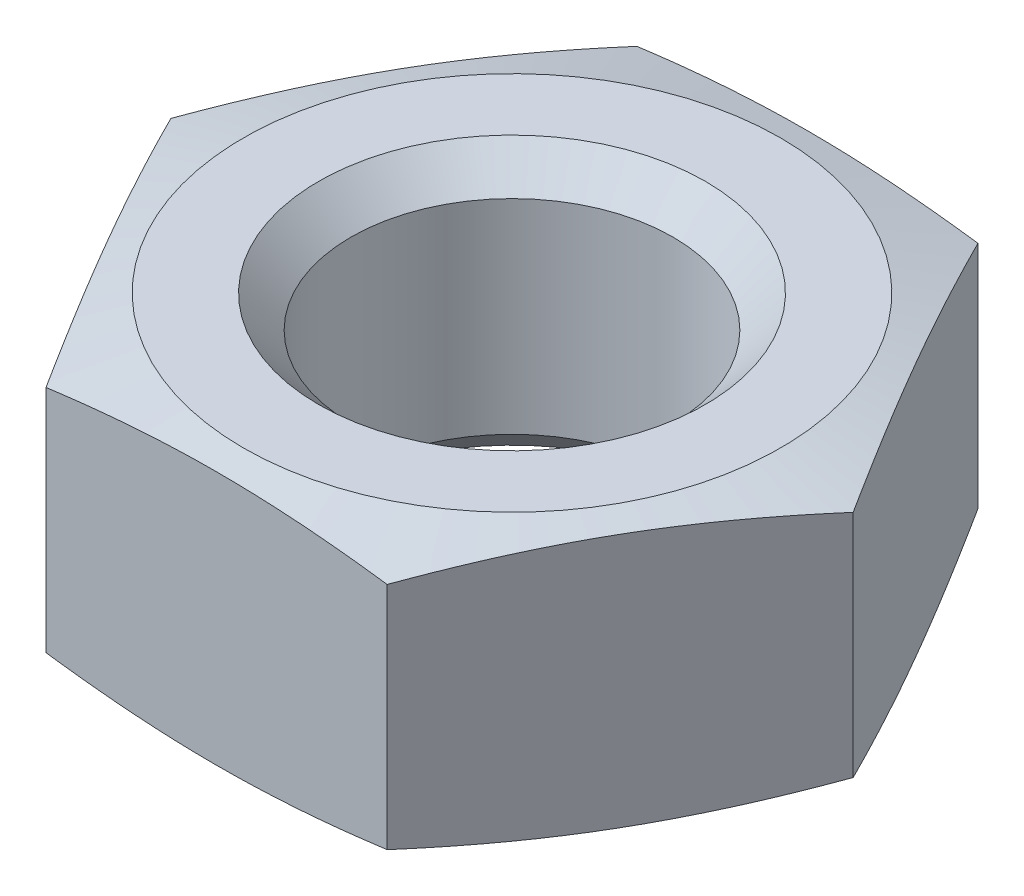
from build123d import *

# Parameters (mm, degrees)
SKETCH1_R      = 1.5
EXTRUDE1_DEPTH = 2.5


with BuildPart() as part:
    # Sketch1 → Extrude1 (new body)
    with BuildSketch(Plane(origin=(0, 0, 0), x_dir=(1, 0, 0), z_dir=(0, 1, 0))):
        Polygon((-3.175426481, 0), (-1.58771324, 2.75), (1.58771324, 2.75), (3.175426481, 0), (1.58771324, -2.75), (-1.58771324, -2.75), align=None)
        with Locations(Location((0, 0, 0), (0, 0, 270))):  # turned: the seam where the file's is
            Circle(SKETCH1_R, mode=Mode.SUBTRACT)
    extrude(amount=EXTRUDE1_DEPTH)

    # Sketch2 → Cut-Revolve1 (revolve, cut)
    with BuildSketch(Plane.XY, mode=Mode.PRIVATE) as cut_revolve1_sk:
        Polygon((1.5, 2.5), (1.8, 2.5), (1.5, 2.2), align=None)
        Polygon((1.5, 0), (1.8, 0), (1.5, 0.3), align=None)
        Polygon((3.175426481, 0), (3.175426481, 0.18097998), (2.5, 0), align=None)
        Polygon((3.175426481, 2.5), (3.175426481, 2.31902002), (2.5, 2.5), align=None)
    revolve(cut_revolve1_sk.sketch.rotate(Axis((0, 0, 0), (0, 1, 0)), 90), axis=Axis((0, 0, 0), (0, 1, 0)), mode=Mode.SUBTRACT)  # turned: the seam where the file's is


solid = part.part
